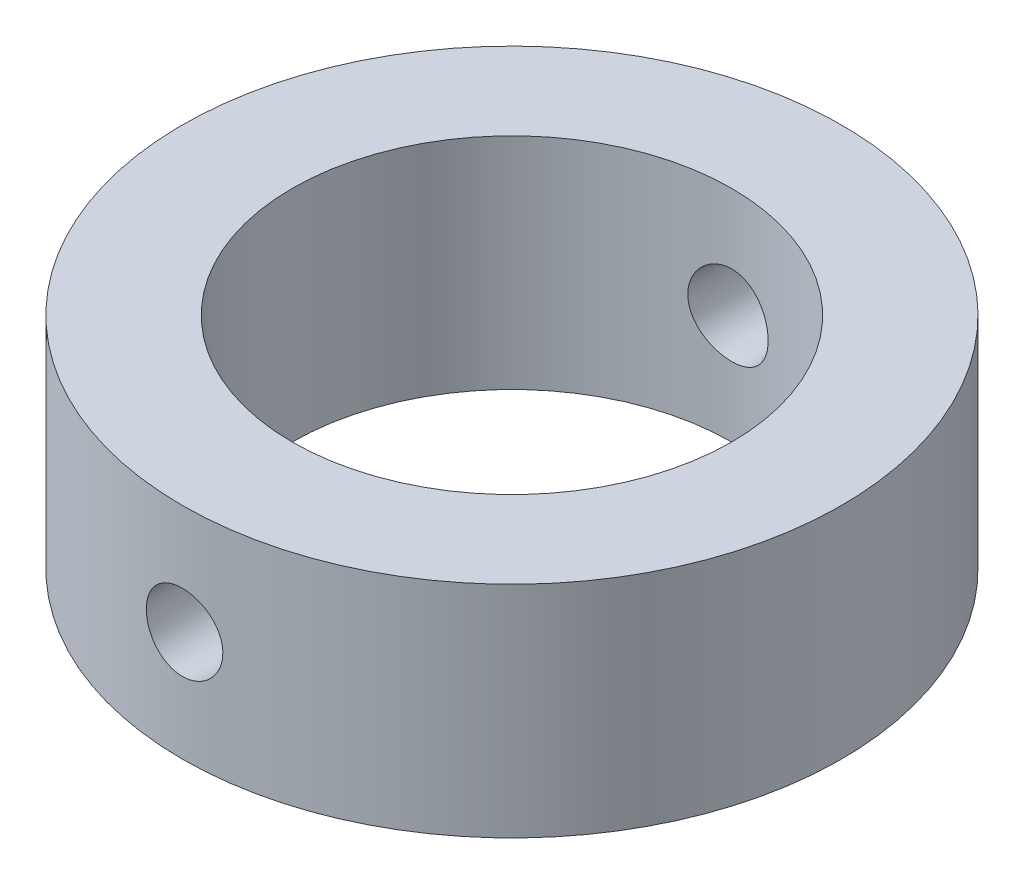
from build123d import *

# Parameters (mm, degrees)
SKETCH3_R                    = 15
SKETCH3_R_2                  = 10
BOSS_EXTRUDE1_DEPTH          = 10
SKETCH4_R                    = 2
CUT_EXTRUDE1_DEPTH           = 21
CUT_EXTRUDE1_TAPER           = 1
CUT_EXTRUDE1_OTHER_WAY_DEPTH = 19
CUT_EXTRUDE1_OTHER_WAY_TAPER = 1


with BuildPart() as part:
    # Sketch3 → Boss-Extrude1 (new body)
    with BuildSketch(Plane(origin=(0, 0, 0), x_dir=(1, 0, 0), z_dir=(0, 1, 0))):
        Circle(SKETCH3_R)
        Circle(SKETCH3_R_2, mode=Mode.SUBTRACT)
    extrude(amount=BOSS_EXTRUDE1_DEPTH)

    # Sketch4 → Cut-Extrude1 (cut)
    with BuildSketch(Plane.XY):
        with Locations((0, 5)):
            Circle(SKETCH4_R)
    extrude(amount=-CUT_EXTRUDE1_DEPTH, taper=CUT_EXTRUDE1_TAPER, mode=Mode.SUBTRACT)

    # Sketch4 → Cut-Extrude1 other way (cut)
    with BuildSketch(Plane.XY):
        with Locations((0, 5)):
            Circle(SKETCH4_R)
    extrude(amount=CUT_EXTRUDE1_OTHER_WAY_DEPTH, taper=CUT_EXTRUDE1_OTHER_WAY_TAPER, mode=Mode.SUBTRACT)


solid = part.part
